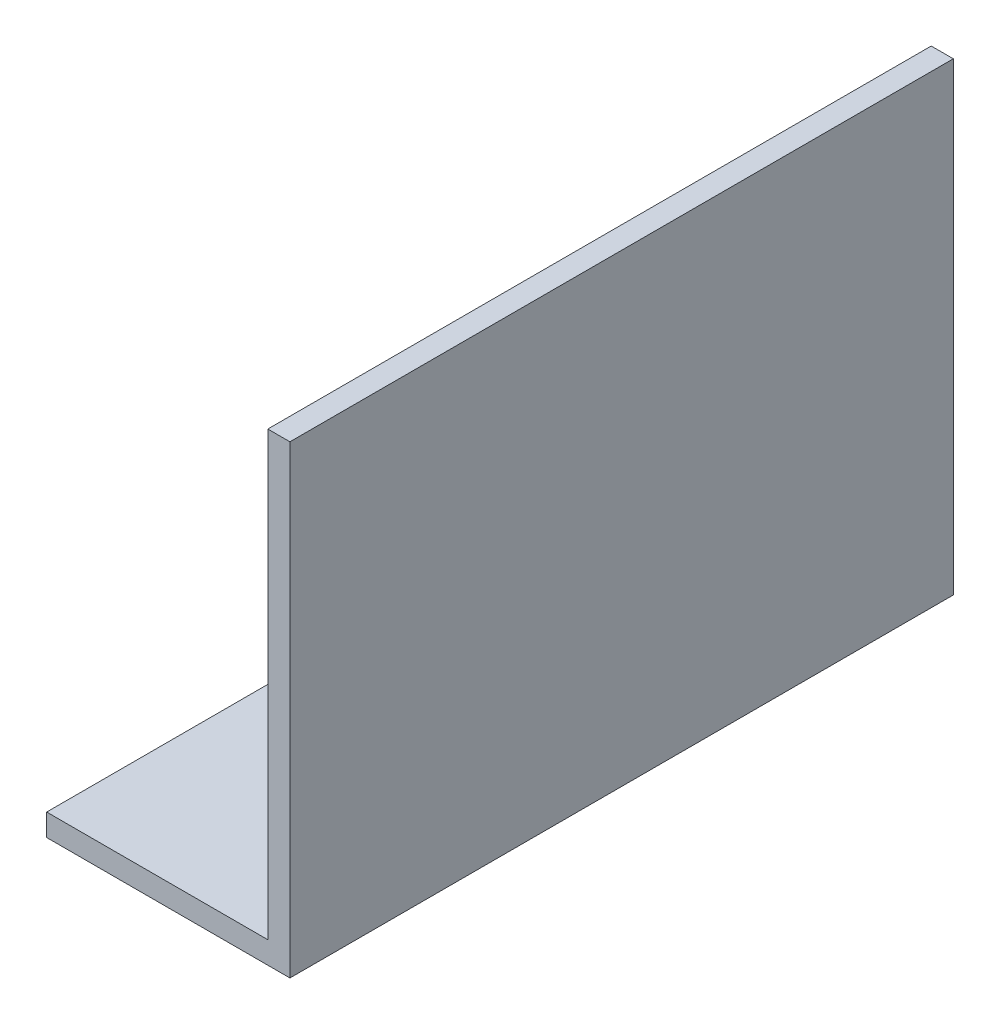
from build123d import *

# Parameters (mm, degrees)
EXTRU_MINCE1_DEPTH = 60


with BuildPart() as part:
    # Esquisse1 → Extru.-Mince1 (new body)
    with BuildSketch(Plane.XY):
        Polygon((0, 0), (20, 0), (20, 40), (22, 40), (22, -2), (0, -2), align=None)
    extrude(amount=EXTRU_MINCE1_DEPTH)


solid = part.part
